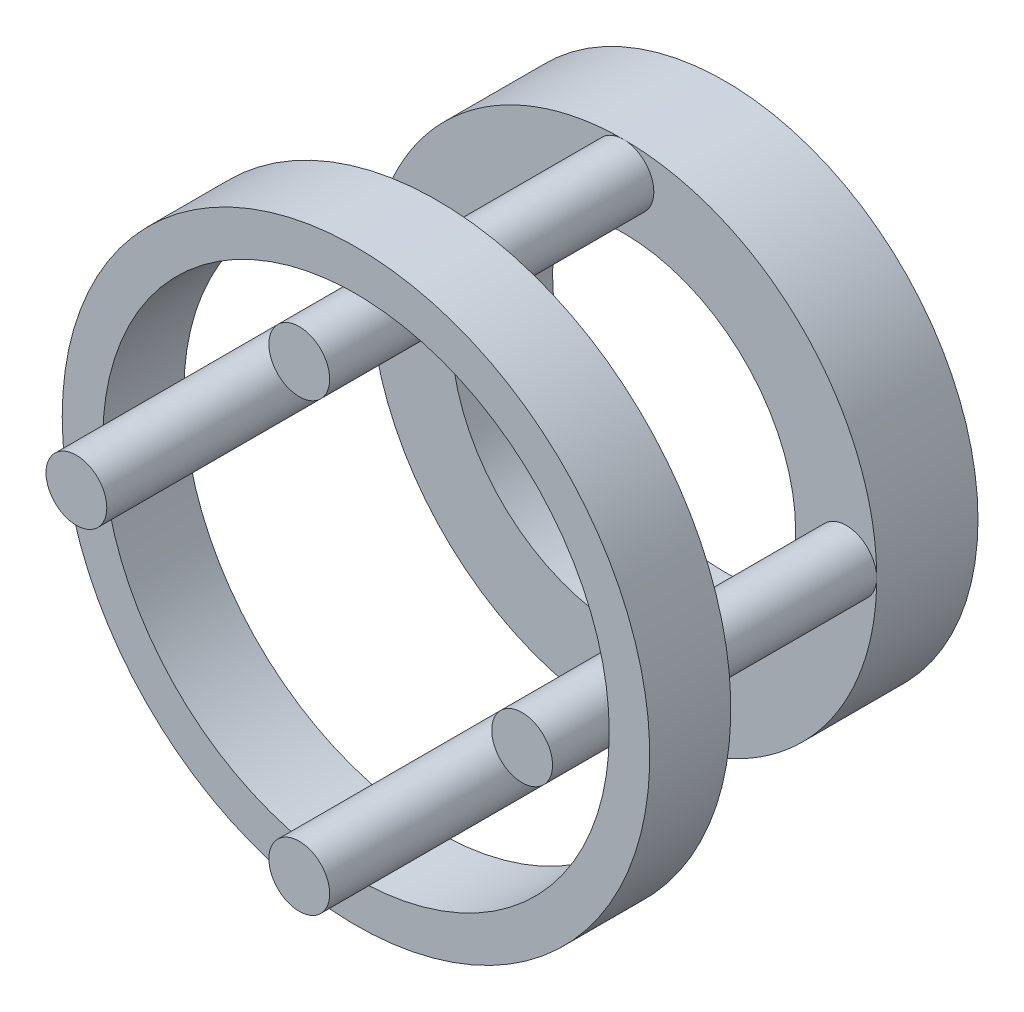
from build123d import *

# Parameters (mm, degrees)
BOSS_EXTRUDE1_DEPTH      = 3
BOSS_EXTRUDE1_DEPTH_BACK = 2
SKETCH1_R                = 12.5
SKETCH2_R                = 8.5
CUT_EXTRUDE1_DEPTH       = 23
SKETCH3_R                = 1.5
BOSS_EXTRUDE2_DEPTH      = 16
SKETCH4_R                = 14.5
SKETCH4_R_2              = 12.5
BOSS_EXTRUDE4_DEPTH      = 4
SKETCH5_R                = 1.5
CUT_EXTRUDE2_DEPTH       = 11


with BuildPart() as part:
    # Sketch1 → Boss-Extrude1 (new, two sides: drawn at the far end of the back side and taken through both)
    with BuildSketch(Plane.XY.offset(-BOSS_EXTRUDE1_DEPTH_BACK)):
        Circle(SKETCH1_R)
    extrude(amount=BOSS_EXTRUDE1_DEPTH + BOSS_EXTRUDE1_DEPTH_BACK)

    # Sketch2 → Cut-Extrude1 (cut)
    with BuildSketch(Plane(origin=(0, 0, -2), x_dir=(-1, 0, 0), z_dir=(0, 0, -1))):
        Circle(SKETCH2_R)
    extrude(amount=-CUT_EXTRUDE1_DEPTH, mode=Mode.SUBTRACT)

    # Sketch3 → Boss-Extrude2 (add)
    with BuildSketch(Plane.XY.offset(3)):
        with Locations((0, 11)):
            Circle(SKETCH3_R)
        with Locations((11, 0)):
            Circle(SKETCH3_R)
        with Locations((0, -11)):
            Circle(SKETCH3_R)
        with Locations((-11, 0)):
            Circle(SKETCH3_R)
    extrude(amount=BOSS_EXTRUDE2_DEPTH)

    # Sketch5 → Cut-Extrude2 (cut)
    with BuildSketch(Plane(origin=(0, 0, 0), x_dir=(1, 0, 0), z_dir=(0, 1, 0))):
        with Locations((0, -0.5)):
            Circle(SKETCH5_R)
    extrude(amount=CUT_EXTRUDE2_DEPTH, mode=Mode.SUBTRACT)


with BuildPart() as body_2:
    # Sketch4 → Boss-Extrude4 (new body)
    with BuildSketch(Plane(origin=(0, 0, 12.2), x_dir=(-1, 0, 0), z_dir=(0, 0, -1))):
        Circle(SKETCH4_R)
        Circle(SKETCH4_R_2, mode=Mode.SUBTRACT)
    extrude(amount=-BOSS_EXTRUDE4_DEPTH)


solid = Compound([part.part, body_2.part])
